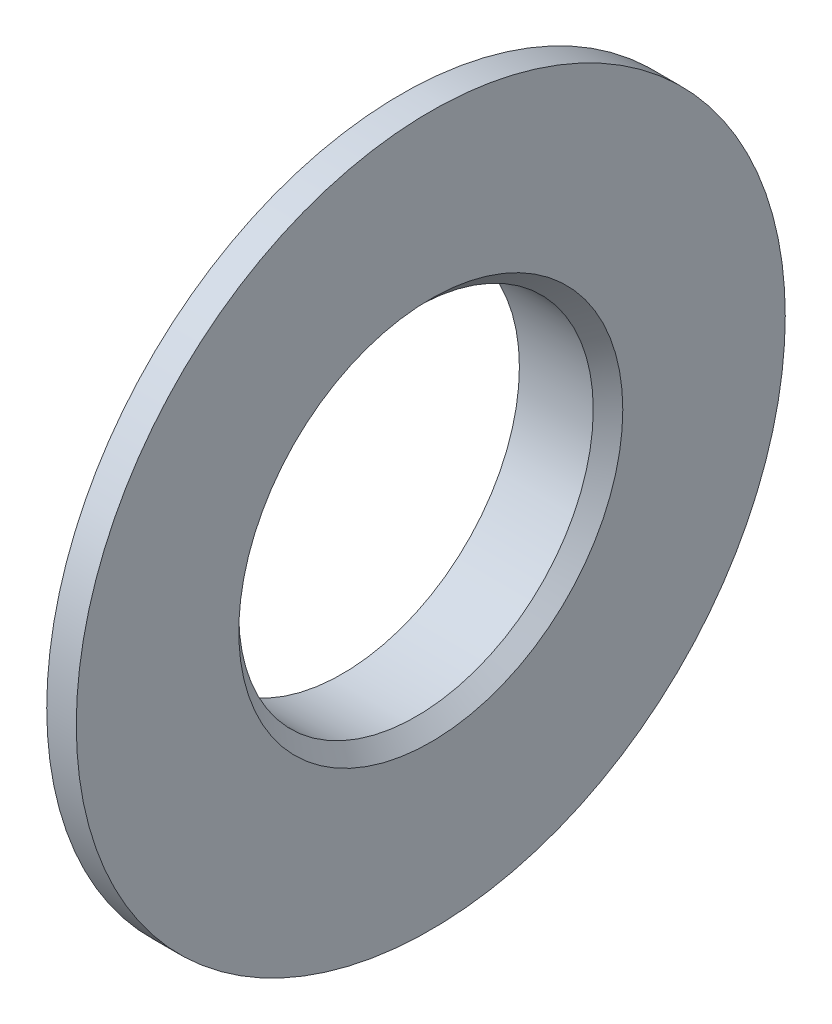
from build123d import *

# Parameters (mm, degrees)
CHAMFER1_SIZE = 0.5


with BuildPart() as part:
    # Sketch1 → Revolve1 (revolve)
    with BuildSketch(Plane.XY):
        Polygon((0, 6), (-1, 6), (-3, 6), (-3, 7), (-1, 7), (-1, 12), (0, 12), align=None)
    revolve(axis=Axis((0, 0, 0), (-1, 0, 0)))

    # Chamfer1
    chamfer1_edges = [part.edges().sort_by_distance(p)[0] for p in [
        (0, -6, 0),
    ]]
    chamfer(chamfer1_edges, length=CHAMFER1_SIZE)


solid = part.part
